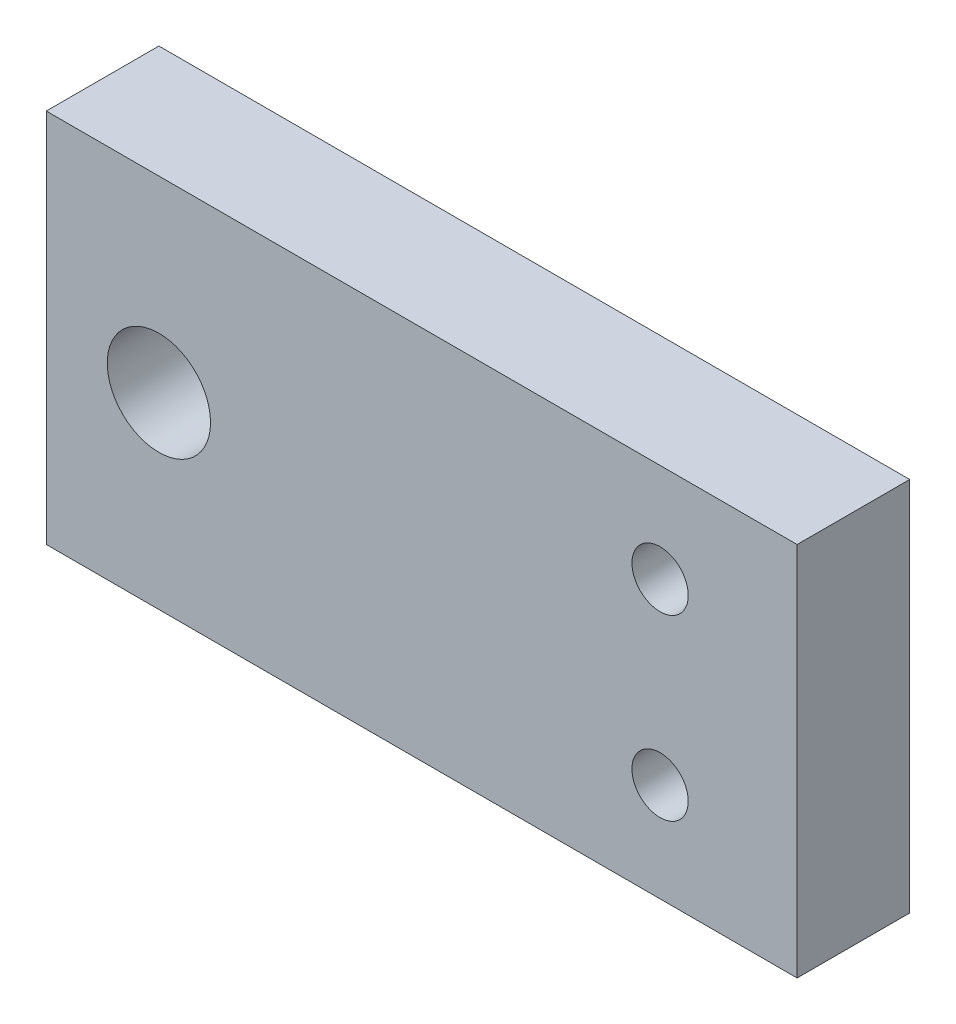
from build123d import *

# Parameters (mm, degrees)
CROQUIS1_W              = 40
CROQUIS1_H              = 20
SALIENTE_EXTRUIR1_DEPTH = 6
CROQUIS2_W              = 18
CROQUIS2_H              = 4.5
SALIENTE_EXTRUIR2_DEPTH = 1.5
CROQUIS3_R              = 2.75
CORTAR_EXTRUIR1_DEPTH   = 8.5
CROQUIS4_R              = 1.5
CORTAR_EXTRUIR2_DEPTH   = 8.5
CORTAR_EXTRUIR3_DEPTH   = 2


with BuildPart() as part:
    # Croquis1 → Saliente-Extruir1 (new body)
    with BuildSketch(Plane.XY):
        with Locations((20, 0)):
            Rectangle(CROQUIS1_W, CROQUIS1_H)
    extrude(amount=SALIENTE_EXTRUIR1_DEPTH)

    # Croquis2 → Saliente-Extruir2 (add)
    with BuildSketch(Plane(origin=(0, 0, 0), x_dir=(-1, 0, 0), z_dir=(0, 0, -1))):
        with Locations((-20, 0)):
            Rectangle(CROQUIS2_W, CROQUIS2_H)
    extrude(amount=SALIENTE_EXTRUIR2_DEPTH)

    # Croquis3 → Cortar-Extruir1 (cut, through all)
    with BuildSketch(Plane.XY.offset(6)):
        with Locations((6, 0)):
            Circle(CROQUIS3_R)
    extrude(amount=-CORTAR_EXTRUIR1_DEPTH, mode=Mode.SUBTRACT)

    # Croquis4 → Cortar-Extruir2 (cut, through all)
    with BuildSketch(Plane.XY.offset(6)):
        with Locations((32.7, 4.75)):
            Circle(CROQUIS4_R)
        with Locations((32.7, -4.75)):
            Circle(CROQUIS4_R)
    extrude(amount=-CORTAR_EXTRUIR2_DEPTH, mode=Mode.SUBTRACT)

    # Croquis5 → Cortar-Extruir3 (cut)
    with BuildSketch(Plane(origin=(0, 0, 0), x_dir=(-1, 0, 0), z_dir=(0, 0, -1))):
        Polygon((-29.524573519, 4.75), (-31.11228676, 7.5), (-34.28771324, 7.5), (-35.875426481, 4.75), (-34.28771324, 2), (-31.11228676, 2), align=None)
        Polygon((-29.524573519, -4.75), (-31.11228676, -2), (-34.28771324, -2), (-35.875426481, -4.75), (-34.28771324, -7.5), (-31.11228676, -7.5), align=None)
    extrude(amount=-CORTAR_EXTRUIR3_DEPTH, mode=Mode.SUBTRACT)


solid = part.part
